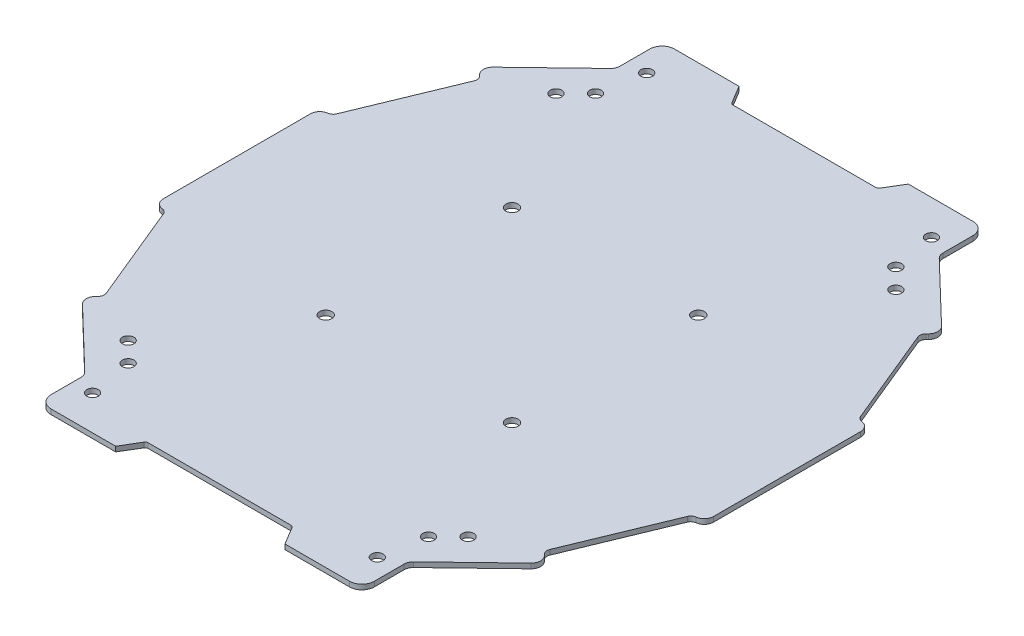
from build123d import *

# Parameters (mm, degrees)
SKETCH1_R        = 1.85915493
SKETCH1_R_2      = 1.983111479
EXTRUSION1_DEPTH = 1.6
FILLET1_R        = 1
FILLET2_R        = 4
FILLET3_R        = 3
FILLET4_R        = 3
FILLET5_R        = 2
FILLET6_R        = 2
FILLET7_R        = 3
FILLET8_R        = 3
FILLET9_R        = 2
FILLET10_R       = 2
FILLET11_R       = 3


with BuildPart() as part:
    # Sketch1 → Extrusion1 (new body)
    with BuildSketch(Plane(origin=(0, 0, 0), x_dir=(-1, 0, 0), z_dir=(0, 1, 0))):
        Polygon((74.087520418, 321.088295015), (70.369210559, 327.285477572), (45.580478165, 327.285477572), (45.580478165, 312.412238135), (23.246043749, 290.934342561), (26.682507041, 287.360833055), (12.735407819, 253.538985229), (9.017097883, 253.538985229), (9.017097883, 226.891111382), (9.017097883, 200.243237534), (12.735407819, 200.243237534), (26.682507041, 166.421389708), (23.246043749, 162.847880202), (45.580478165, 141.369984628), (45.580478165, 126.496745191), (70.369210559, 126.496745191), (74.087520418, 132.693927748), (97.636816193, 132.693927748), (121.186111968, 132.693927748), (124.904421827, 126.496745191), (149.693154221, 126.496745191), (149.693154221, 141.369984628), (172.027588636, 162.847880202), (168.591125345, 166.421389708), (182.538224567, 200.243237534), (186.256534503, 200.243237534), (186.256534503, 226.891111382), (186.256534503, 253.538985229), (182.538224567, 253.538985229), (168.591125345, 287.360833055), (172.027588636, 290.934342561), (149.693154221, 312.412238135), (149.693154221, 327.285477572), (124.904421827, 327.285477572), (121.186111968, 321.088295015), (97.636816193, 321.088295015), align=None)
        with Locations((49.266182018, 151.62213525)):
            Circle(SKETCH1_R, mode=Mode.SUBTRACT)
        with Locations((51.777661187, 316.130534525)):
            Circle(SKETCH1_R, mode=Mode.SUBTRACT)
        with Locations((49.266182018, 302.160087513)):
            Circle(SKETCH1_R, mode=Mode.SUBTRACT)
        with Locations((143.495971199, 137.651688238)):
            Circle(SKETCH1_R, mode=Mode.SUBTRACT)
        with Locations((146.007450368, 151.62213525)):
            Circle(SKETCH1_R, mode=Mode.SUBTRACT)
        with Locations((143.495971199, 316.130534525)):
            Circle(SKETCH1_R, mode=Mode.SUBTRACT)
        with Locations((146.007450368, 302.160087513)):
            Circle(SKETCH1_R, mode=Mode.SUBTRACT)
        with Locations((51.777661187, 137.651688238)):
            Circle(SKETCH1_R, mode=Mode.SUBTRACT)
        with Locations((67.636816193, 196.891111382)):
            Circle(SKETCH1_R_2, mode=Mode.SUBTRACT)
        with Locations((67.636816193, 256.891111382)):
            Circle(SKETCH1_R_2, mode=Mode.SUBTRACT)
        with Locations((42.888078851, 158.000238416)):
            Circle(SKETCH1_R, mode=Mode.SUBTRACT)
        with Locations((152.385553534, 295.781984347)):
            Circle(SKETCH1_R, mode=Mode.SUBTRACT)
        with Locations((42.888078851, 295.781984347)):
            Circle(SKETCH1_R, mode=Mode.SUBTRACT)
        with Locations((127.636816193, 256.891111382)):
            Circle(SKETCH1_R_2, mode=Mode.SUBTRACT)
        with Locations((152.385553534, 158.000238416)):
            Circle(SKETCH1_R, mode=Mode.SUBTRACT)
        with Locations((127.636816193, 196.891111382)):
            Circle(SKETCH1_R_2, mode=Mode.SUBTRACT)
    extrude(amount=EXTRUSION1_DEPTH)

    # Fillet1
    fillet1_edges = [part.edges().sort_by_distance(p)[0] for p in [
        (-121.186111968, 0.8, 321.088295015),
        (-121.186111968, 0.8, 132.693927748),
        (-74.087520418, 0.8, 132.693927748),
        (-74.087520418, 0.8, 321.088295015),
    ]]
    fillet(fillet1_edges, radius=FILLET1_R)

    # Fillet2
    fillet2_edges = [part.edges().sort_by_distance(p)[0] for p in [
        (-149.693154221, 0.8, 327.285477572),
        (-149.693154221, 0.8, 126.496745191),
        (-45.580478165, 0.8, 126.496745191),
        (-45.580478165, 0.8, 327.285477572),
    ]]
    fillet(fillet2_edges, radius=FILLET2_R)

    # Fillet3
    fillet3_edges = [part.edges().sort_by_distance(p)[0] for p in [
        (-149.693154221, 0.8, 312.412238135),
        (-149.693154221, 0.8, 141.369984628),
        (-45.580478165, 0.8, 141.369984628),
        (-45.580478165, 0.8, 312.412238135),
    ]]
    fillet(fillet3_edges, radius=FILLET3_R)

    # Fillet4
    fillet4_edges = [part.edges().sort_by_distance(p)[0] for p in [
        (-172.027588636, 0.8, 290.934342561),
    ]]
    fillet(fillet4_edges, radius=FILLET4_R)

    # Fillet5
    fillet5_edges = [part.edges().sort_by_distance(p)[0] for p in [
        (-168.591125345, 0.8, 287.360833055),
    ]]
    fillet(fillet5_edges, radius=FILLET5_R)

    # Fillet6
    fillet6_edges = [part.edges().sort_by_distance(p)[0] for p in [
        (-26.682507041, 0.8, 287.360833055),
    ]]
    fillet(fillet6_edges, radius=FILLET6_R)

    # Fillet7
    fillet7_edges = [part.edges().sort_by_distance(p)[0] for p in [
        (-23.246043749, 0.8, 290.934342561),
    ]]
    fillet(fillet7_edges, radius=FILLET7_R)

    # Fillet8
    fillet8_edges = [part.edges().sort_by_distance(p)[0] for p in [
        (-172.027588636, 0.8, 162.847880202),
        (-23.246043749, 0.8, 162.847880202),
    ]]
    fillet(fillet8_edges, radius=FILLET8_R)

    # Fillet9
    fillet9_edges = [part.edges().sort_by_distance(p)[0] for p in [
        (-168.591125345, 0.8, 166.421389708),
        (-26.682507041, 0.8, 166.421389708),
    ]]
    fillet(fillet9_edges, radius=FILLET9_R)

    # Fillet10
    fillet10_edges = [part.edges().sort_by_distance(p)[0] for p in [
        (-182.538224567, 0.8, 253.538985229),
        (-182.538224567, 0.8, 200.243237534),
        (-12.735407819, 0.8, 200.243237534),
        (-12.735407819, 0.8, 253.538985229),
    ]]
    fillet(fillet10_edges, radius=FILLET10_R)

    # Fillet11
    fillet11_edges = [part.edges().sort_by_distance(p)[0] for p in [
        (-186.256534503, 0.8, 200.243237534),
        (-186.256534503, 0.8, 253.538985229),
        (-9.017097883, 0.8, 253.538985229),
        (-9.017097883, 0.8, 200.243237534),
    ]]
    fillet(fillet11_edges, radius=FILLET11_R)


solid = part.part
